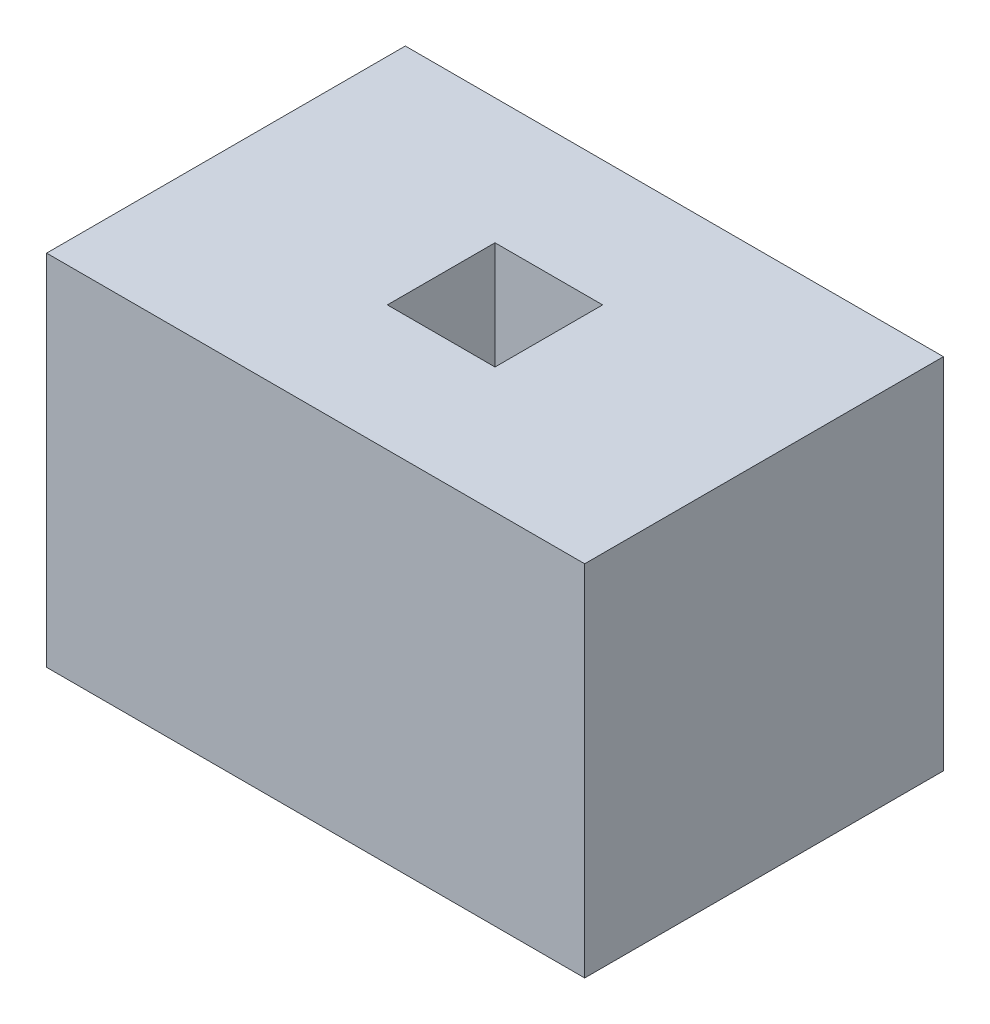
from build123d import *

# Parameters (mm, degrees)
SKETCH1_W           = 3000
SKETCH1_H           = 2000
BOSS_EXTRUDE1_DEPTH = 2000
SKETCH8_W           = 600
SKETCH8_H           = 600
CUT_EXTRUDE1_DEPTH  = 600


with BuildPart() as part:
    # Sketch1 → Boss-Extrude1 (new body)
    with BuildSketch(Plane(origin=(0, 0, 0), x_dir=(1, 0, 0), z_dir=(0, 1, 0))):
        Rectangle(SKETCH1_W, SKETCH1_H)
    extrude(amount=BOSS_EXTRUDE1_DEPTH)

    # Sketch8 → Cut-Extrude1 (cut)
    with BuildSketch(Plane(origin=(0, 2000, 0), x_dir=(1, 0, 0), z_dir=(0, 1, 0))):
        Rectangle(SKETCH8_W, SKETCH8_H)
    extrude(amount=-CUT_EXTRUDE1_DEPTH, mode=Mode.SUBTRACT)


solid = part.part
